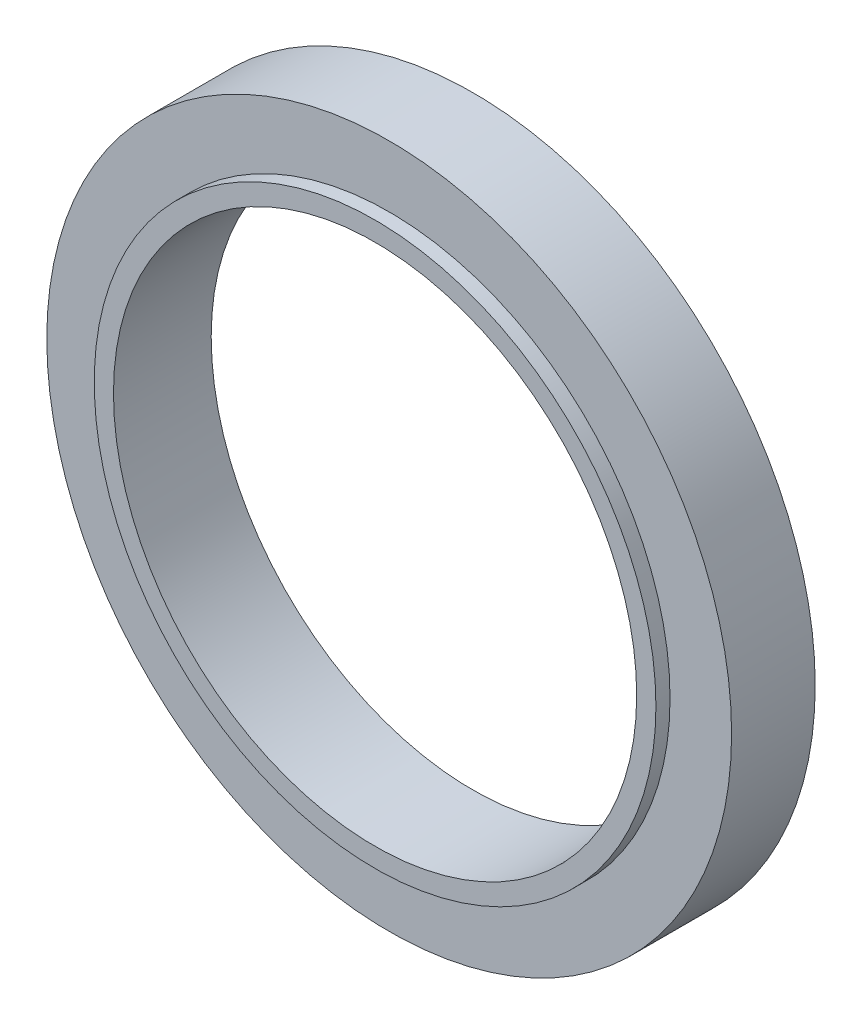
from build123d import *

# Parameters (mm, degrees)
SKETCH1_R           = 109.5
SKETCH1_R_2         = 102
BOSS_EXTRUDE1_DEPTH = 38.1
SKETCH1_3_R         = 133.5
SKETCH1_3_R_2       = 109.5
BOSS_EXTRUDE2_DEPTH = 32.6


with BuildPart() as part:
    # Sketch1 → Boss-Extrude1 (new body)
    with BuildSketch(Plane.XY):
        Circle(SKETCH1_R)
        Circle(SKETCH1_R_2, mode=Mode.SUBTRACT)
    extrude(amount=BOSS_EXTRUDE1_DEPTH)

    # Sketch1_3 → Boss-Extrude2 (add)
    with BuildSketch(Plane.XY):
        Circle(SKETCH1_3_R)
        Circle(SKETCH1_3_R_2, mode=Mode.SUBTRACT)
    extrude(amount=BOSS_EXTRUDE2_DEPTH)


solid = part.part
